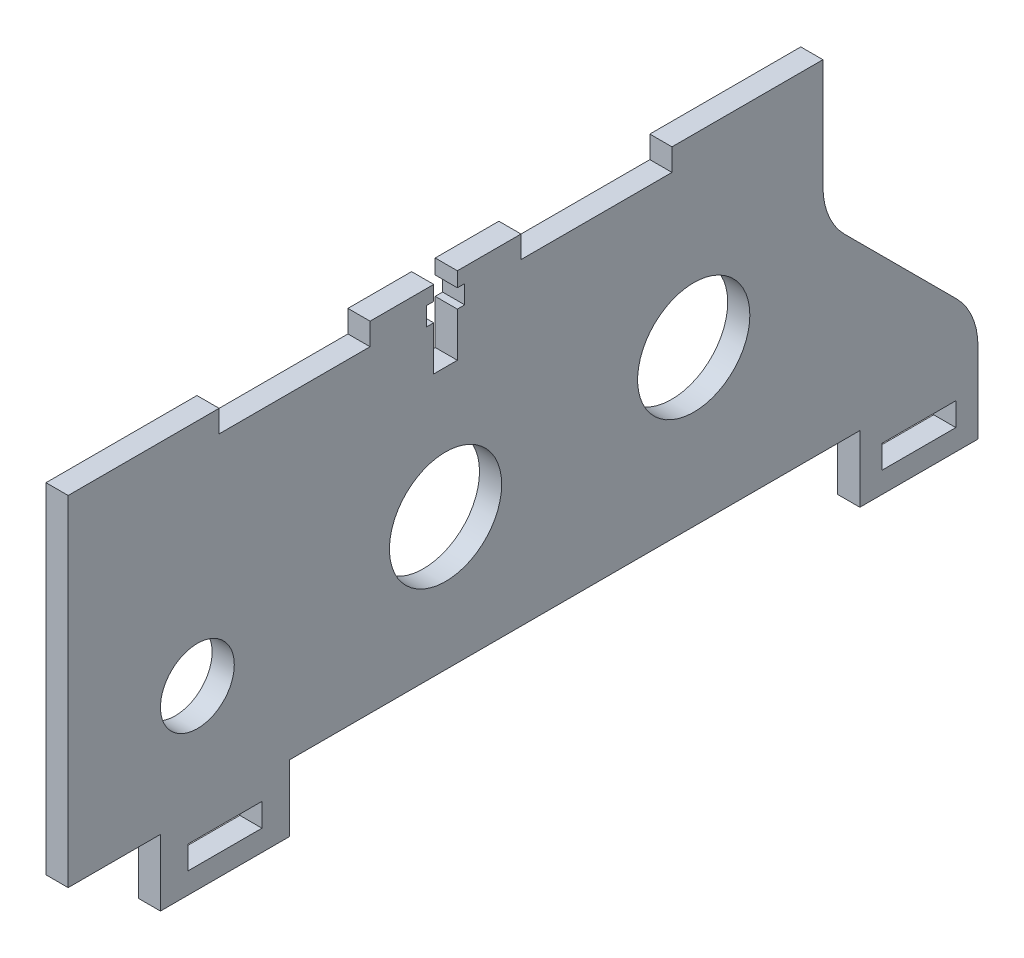
from build123d import *

# Parameters (mm, degrees)
SKETCH1_R               = 7.6
SKETCH1_R_2             = 5
SKETCH1_W               = 10
SKETCH1_H               = 3.15
BOSS_EXTRUDE1_DEPTH     = 3
FILLET1_R               = 10
SKETCH2_W               = 3.2
SKETCH2_H               = 6
SKETCH2_H_2             = 2.5
SKETCH2_W_2             = 1
SKETCH2_H_3             = 2
CUT_EXTRUDE1_DEPTH      = 1
CUT_EXTRUDE1_DEPTH_BACK = 4


with BuildPart() as part:
    # Sketch1 → Boss-Extrude1 (new body)
    with BuildSketch(Plane(origin=(0, 0, 0), x_dir=(0, 0, -1), z_dir=(1, 0, 0))):
        Polygon((102.223805307, 6), (123.223805307, 6), (102.223805307, 27), align=None)
        Polygon((102.223805307, 6), (123.223805307, 6), (123.223805307, -9), (107.223805307, -9), (107.223805307, 0), (30, 0), (30, -9), (12.5, -9), (12.5, 0), (0, 0), (0, 46), (20.444761061, 46), (20.444761061, 43), (40.889522123, 43), (40.889522123, 46), (61.334283184, 46), (61.334283184, 43), (81.779044246, 43), (81.779044246, 46), (102.223805307, 46), align=None)
        with Locations((84.723805307, 21)):
            Circle(SKETCH1_R, mode=Mode.SUBTRACT)
        with Locations((51.111902654, 17.95)):
            Circle(SKETCH1_R, mode=Mode.SUBTRACT)
        with Locations((17.5, 14.9)):
            Circle(SKETCH1_R_2, mode=Mode.SUBTRACT)
        with Locations((115.223805307, -4.575)):
            Rectangle(SKETCH1_W, SKETCH1_H, mode=Mode.SUBTRACT)
        with Locations((21.25, -4.575)):
            Rectangle(SKETCH1_W, SKETCH1_H, mode=Mode.SUBTRACT)
    extrude(amount=BOSS_EXTRUDE1_DEPTH)

    # Fillet1
    fillet1_edges = [part.edges().sort_by_distance(p)[0] for p in [
        (1.5, 6, -123.223805307),
        (1.5, 27, -102.223805307),
    ]]
    fillet(fillet1_edges, radius=FILLET1_R)

    # Sketch2 → Cut-Extrude1 (cut, two sides)
    with BuildSketch(Plane(origin=(3, 0, 0), x_dir=(0, 0, -1), z_dir=(1, 0, 0))) as cut_extrude1_sk:
        with Locations((51.111902654, 38.5)):
            Rectangle(SKETCH2_W, SKETCH2_H)
        with Locations((51.111902654, 42.75)):
            Rectangle(SKETCH2_W, SKETCH2_H_2)
        with Locations((49.011902654, 42.75)):
            Rectangle(SKETCH2_W_2, SKETCH2_H_2)
        with Locations((51.111902654, 45)):
            Rectangle(SKETCH2_W, SKETCH2_H_3)
        with Locations((53.211902654, 42.75)):
            Rectangle(SKETCH2_W_2, SKETCH2_H_2)
    extrude(amount=CUT_EXTRUDE1_DEPTH, mode=Mode.SUBTRACT)
    extrude(cut_extrude1_sk.sketch, amount=-CUT_EXTRUDE1_DEPTH_BACK, mode=Mode.SUBTRACT)


solid = part.part
